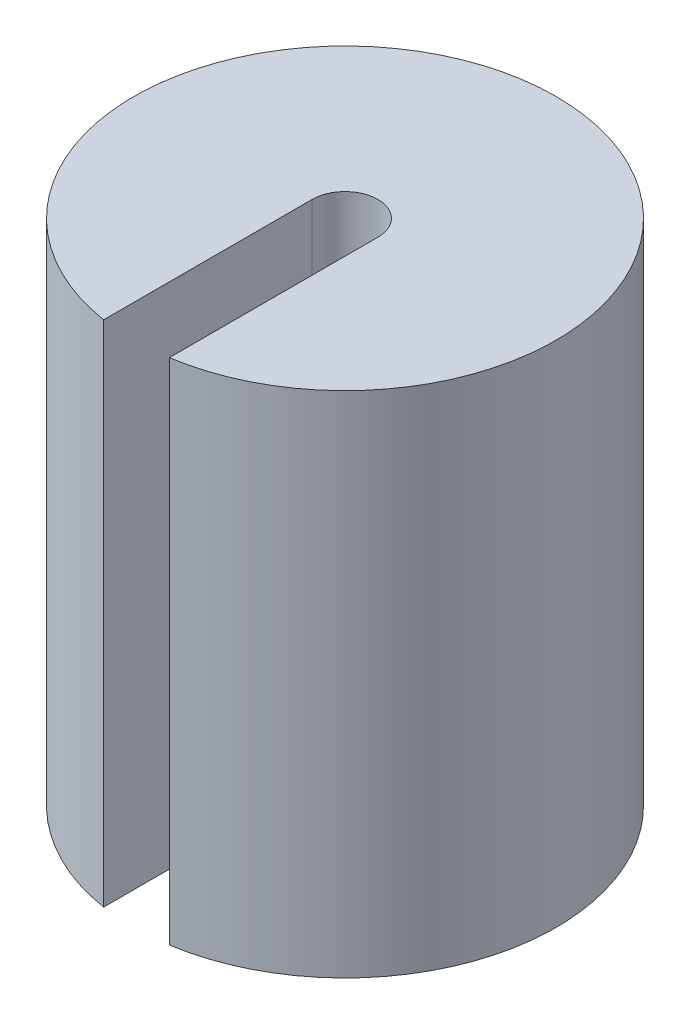
from build123d import *

# Parameters (mm, degrees)
SKETCH1_R           = 20.75
BOSS_EXTRUDE1_DEPTH = 50
CUT_EXTRUDE1_DEPTH  = 60.6


with BuildPart() as part:
    # Sketch1 → Boss-Extrude1 (new body)
    with BuildSketch(Plane(origin=(0, 0, 0), x_dir=(1, 0, 0), z_dir=(0, 1, 0))):
        Circle(SKETCH1_R)
    extrude(amount=BOSS_EXTRUDE1_DEPTH)

    # Sketch2 → Cut-Extrude1 (cut)
    with BuildSketch(Plane(origin=(0, 50, 0), x_dir=(1, 0, 0), z_dir=(0, 1, 0))):
        with BuildLine():
            Line((-3.225, 0), (-3.225, -23.125803827))
            Line((-3.225, -23.125803827), (3.225, -23.125803827))
            Line((3.225, -23.125803827), (3.225, 0))
            ThreePointArc((3.225, 0), (0, 3.225), (-3.225, 0))
        make_face()
    extrude(amount=-CUT_EXTRUDE1_DEPTH, mode=Mode.SUBTRACT)


solid = part.part
